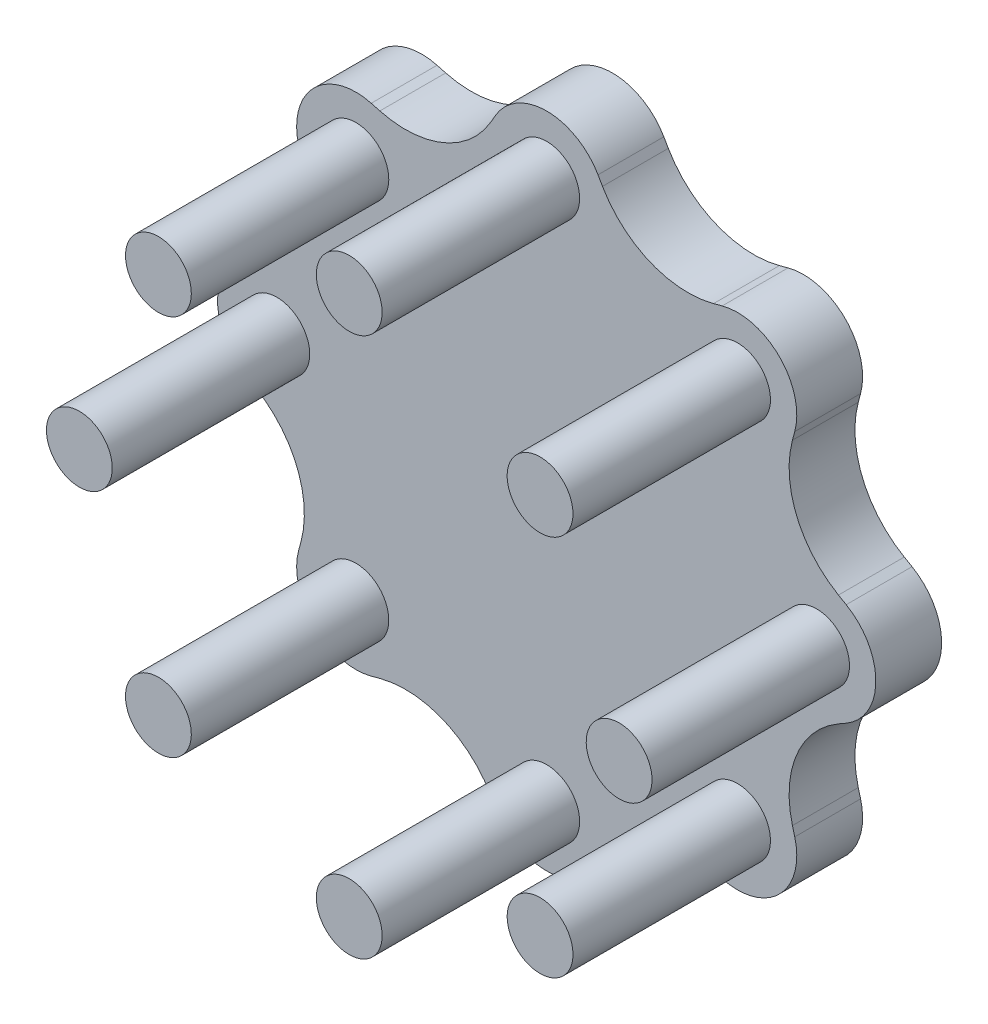
from build123d import *

# Parameters (mm, degrees)
SKETCH2_R           = 25
PINION_DEPTH        = 200
PINION_BASE_DEPTH   = 50
CIRPATTERN1_COUNT   = 8
SKETCH1_R           = 180
BOSS_EXTRUDE1_DEPTH = 50
FILLET1_R           = 75


with BuildPart() as part:
    # Sketch2 → pinion (new body)
    with BuildSketch(Plane(origin=(0, 0, 0), x_dir=(0, 1, 0), z_dir=(0, 0, 1))):
        with Locations((-205, 0)):
            Circle(SKETCH2_R)
    extrude(amount=PINION_DEPTH)

    # Sketch2_3 → pinion base (add)
    with BuildSketch(Plane(origin=(0, 0, 0), x_dir=(0, 1, 0), z_dir=(0, 0, 1))):
        with BuildLine():
            Line((-227.5, 38.97114317), (-84.370095606, 121.607232002))
            Line((-84.370095606, 121.607232002), (-84.370095606, -121.607232002))
            Line((-84.370095606, -121.607232002), (-227.5, -38.97114317))
            ThreePointArc((-227.5, -38.97114317), (-250, 0), (-227.5, 38.97114317))
        make_face()
    extrude(amount=PINION_BASE_DEPTH)


with BuildPart() as cirpattern1_1:
    # CirPattern1: pattern copy
    add(part.part.rotate(Axis((0, 0, 210), (0, 0, -1)), 1 * 360 / CIRPATTERN1_COUNT))


with BuildPart() as cirpattern1_2:
    # CirPattern1: pattern copy
    add(part.part.rotate(Axis((0, 0, 210), (0, 0, -1)), 2 * 360 / CIRPATTERN1_COUNT))


with BuildPart() as cirpattern1_3:
    # CirPattern1: pattern copy
    add(part.part.rotate(Axis((0, 0, 210), (0, 0, -1)), 3 * 360 / CIRPATTERN1_COUNT))


with BuildPart() as cirpattern1_4:
    # CirPattern1: pattern copy
    add(part.part.rotate(Axis((0, 0, 210), (0, 0, -1)), 4 * 360 / CIRPATTERN1_COUNT))


with BuildPart() as cirpattern1_5:
    # CirPattern1: pattern copy
    add(part.part.rotate(Axis((0, 0, 210), (0, 0, -1)), 5 * 360 / CIRPATTERN1_COUNT))


with BuildPart() as cirpattern1_6:
    # CirPattern1: pattern copy
    add(part.part.rotate(Axis((0, 0, 210), (0, 0, -1)), 6 * 360 / CIRPATTERN1_COUNT))


with BuildPart() as cirpattern1_7:
    # CirPattern1: pattern copy
    add(part.part.rotate(Axis((0, 0, 210), (0, 0, -1)), 7 * 360 / CIRPATTERN1_COUNT))


with BuildPart() as part_1:
    add(part.part)

    add(cirpattern1_1.part)  # Boss-Extrude1 merges CirPattern1_1

    add(cirpattern1_2.part)  # Boss-Extrude1 merges CirPattern1_2

    add(cirpattern1_3.part)  # Boss-Extrude1 merges CirPattern1_3

    add(cirpattern1_4.part)  # Boss-Extrude1 merges CirPattern1_4

    add(cirpattern1_5.part)  # Boss-Extrude1 merges CirPattern1_5

    add(cirpattern1_6.part)  # Boss-Extrude1 merges CirPattern1_6

    add(cirpattern1_7.part)  # Boss-Extrude1 merges CirPattern1_7
    # Sketch1 → Boss-Extrude1 (add)
    with BuildSketch(Plane(origin=(0, 0, 0), x_dir=(0, 1, 0), z_dir=(0, 0, 1))):
        Circle(SKETCH1_R)
    extrude(amount=BOSS_EXTRUDE1_DEPTH)

    # Fillet1
    fillet1_edges = [part_1.edges().sort_by_distance(p)[0] for p in [
        (-71.148381695, -171.767388028, 25),
        (71.148381695, -171.767388028, 25),
        (171.767388028, -71.148381695, 25),
        (171.767388028, 71.148381695, 25),
        (71.148381695, 171.767388028, 25),
        (-71.148381695, 171.767388028, 25),
        (-171.767388028, 71.148381695, 25),
        (-171.767388028, -71.148381695, 25),
    ]]
    fillet(fillet1_edges, radius=FILLET1_R)


solid = part_1.part
